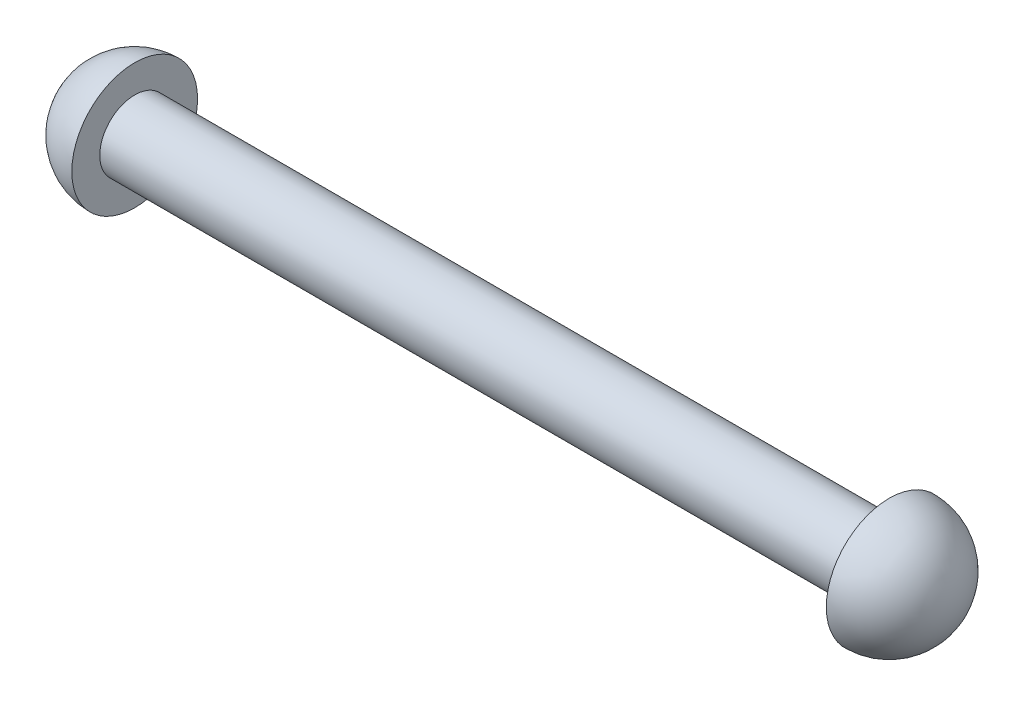
from build123d import *


with BuildPart() as part:
    # Sketch1 → Revolve1 (revolve)
    with BuildSketch(Plane(origin=(0, 0, 0), x_dir=(1, 0, 0), z_dir=(0, 1, 0))):
        with BuildLine():
            ThreePointArc((40.005, 0), (38.331115254, -4.041115254), (34.29, -5.715))
            Line((34.29, -5.715), (34.29, -3.175))
            Line((34.29, -3.175), (-34.29, -3.175))
            Line((-34.29, -3.175), (-34.29, -5.715))
            ThreePointArc((-34.29, -5.715), (-38.331115254, -4.041115254), (-40.005, 0))
            Line((-40.005, 0), (40.005, 0))
        make_face()
    revolve(axis=Axis((-40.005, 0, 0), (1, 0, 0)))


solid = part.part
